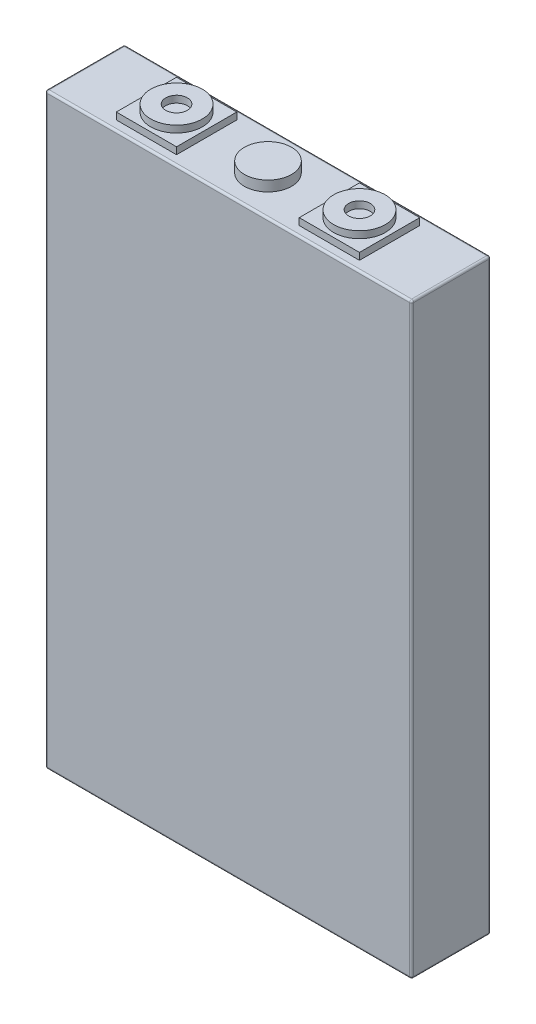
from build123d import *

# Parameters (mm, degrees)
SKETCH1_W             = 135.2
SKETCH1_H             = 29.2
BOSS_EXTRUDE1_DEPTH   = 216.8
SKETCH2_W             = 22.225
SKETCH2_H             = 22.225
BOSS_EXTRUDE2_DEPTH   = 2.54
BOSS_EXTRUDE2_2_DEPTH = 2.54
SKETCH4_R             = 9.525
SKETCH4_R_2           = 4
BOSS_EXTRUDE3_DEPTH   = 2.54
BOSS_EXTRUDE3_2_DEPTH = 2.54
SKETCH5_R             = 8.69809988
BOSS_EXTRUDE4_DEPTH   = 3.81
FILLET1_R             = 0.762


with BuildPart() as part:
    # Sketch1 → Boss-Extrude1 (new body)
    with BuildSketch(Plane(origin=(0, 0, 0), x_dir=(1, 0, 0), z_dir=(0, 1, 0))):
        with Locations((67.6, 14.6)):
            Rectangle(SKETCH1_W, SKETCH1_H)
    extrude(amount=BOSS_EXTRUDE1_DEPTH)

    # Fillet1
    fillet1_edges = [part.edges().sort_by_distance(p)[0] for p in [
        (135.2, 216.8, -14.6),
        (67.6, 216.8, -29.2),
        (0, 216.8, -14.6),
        (67.6, 0, -29.2),
        (135.2, 0, -14.6),
        (67.6, 0, 0),
        (0, 0, -14.6),
        (67.6, 216.8, 0),
        (0, 108.4, -29.2),
        (135.2, 108.4, -29.2),
        (135.2, 108.4, 0),
        (0, 108.4, 0),
    ]]
    fillet(fillet1_edges, radius=FILLET1_R)


with BuildPart() as body_2:
    # Sketch2 → Boss-Extrude2 (new body)
    with BuildSketch(Plane(origin=(0, 216.8, 0), x_dir=(1, 0, 0), z_dir=(0, 1, 0))):
        with Locations((33.85, 14.6)):
            Rectangle(SKETCH2_W, SKETCH2_H)
    extrude(amount=BOSS_EXTRUDE2_DEPTH)


with BuildPart() as body_3:
    # Sketch2 → Boss-Extrude2 2 (new body)
    with BuildSketch(Plane(origin=(0, 216.8, 0), x_dir=(1, 0, 0), z_dir=(0, 1, 0))):
        with Locations((101.35, 14.6)):
            Rectangle(SKETCH2_W, SKETCH2_H)
    extrude(amount=BOSS_EXTRUDE2_2_DEPTH)


with BuildPart() as body_4:
    # Sketch4 → Boss-Extrude3 (new body)
    with BuildSketch(Plane(origin=(0, 219.34, 0), x_dir=(1, 0, 0), z_dir=(0, 1, 0))):
        with Locations(Location((33.85, 14.6, 0), (0, 0, 270))):  # turned: the seam where the file's is
            Circle(SKETCH4_R)
        with Locations(Location((33.85, 14.6, 0), (0, 0, 270))):  # turned: the seam where the file's is
            Circle(SKETCH4_R_2, mode=Mode.SUBTRACT)
    extrude(amount=BOSS_EXTRUDE3_DEPTH)


with BuildPart() as body_5:
    # Sketch4 → Boss-Extrude3 2 (new body)
    with BuildSketch(Plane(origin=(0, 219.34, 0), x_dir=(1, 0, 0), z_dir=(0, 1, 0))):
        with Locations(Location((101.35, 14.6, 0), (0, 0, 270))):  # turned: the seam where the file's is
            Circle(SKETCH4_R)
        with Locations(Location((101.35, 14.6, 0), (0, 0, 270))):  # turned: the seam where the file's is
            Circle(SKETCH4_R_2, mode=Mode.SUBTRACT)
    extrude(amount=BOSS_EXTRUDE3_2_DEPTH)


with BuildPart() as body_6:
    # Sketch5 → Boss-Extrude4 (new body)
    with BuildSketch(Plane(origin=(0, 216.8, 0), x_dir=(1, 0, 0), z_dir=(0, 1, 0))):
        with Locations(Location((67.6, 14.6, 0), (0, 0, 270))):  # turned: the seam where the file's is
            Circle(SKETCH5_R)
    extrude(amount=BOSS_EXTRUDE4_DEPTH)


solid = Compound([part.part, body_2.part, body_3.part, body_4.part, body_5.part, body_6.part])
